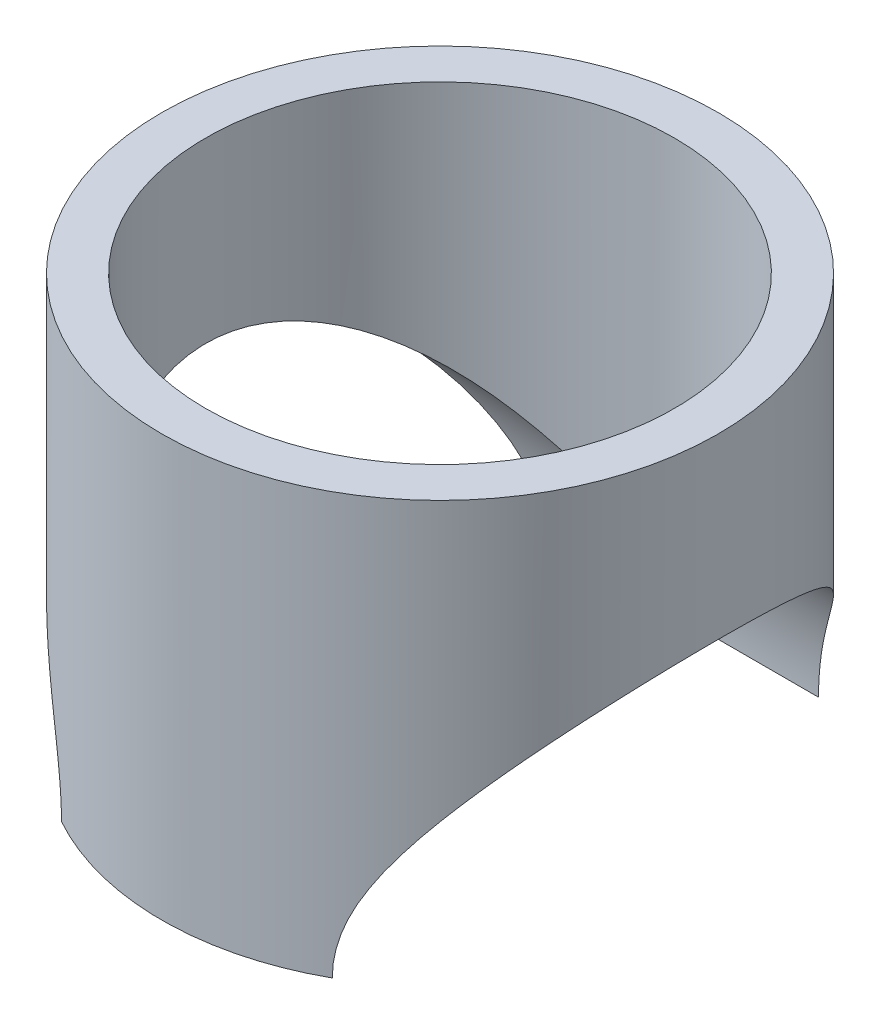
from build123d import *

# Parameters (mm, degrees)
SKETCH1_R           = 24.13
SKETCH1_R_2         = 20.32
BOSS_EXTRUDE1_DEPTH = 18.25625
SKETCH6_W           = 21.082
SKETCH6_H           = 24.13


with BuildPart() as part:
    # Sketch1 → Boss-Extrude1 (new body, symmetric)
    with BuildSketch(Plane(origin=(0, 0, 0), x_dir=(1, 0, 0), z_dir=(0, 1, 0))):
        Circle(SKETCH1_R)
        Circle(SKETCH1_R_2, mode=Mode.SUBTRACT)
    extrude(amount=BOSS_EXTRUDE1_DEPTH, both=True)

    # Sketch6 → 3/32 (1.66) Dowel Hole1 (revolve, cut)
    with BuildSketch(Plane(origin=(0, -18.25625, 0), x_dir=(0, 0, -1), z_dir=(0, 1, 0))):
        with Locations((10.541, 12.065)):
            Rectangle(SKETCH6_W, SKETCH6_H)
    f_3_32_1_66_dowel_hole1 = revolve(axis=Axis((6.35, -18.25625, 0), (-1, 0, 0)), mode=Mode.SUBTRACT)

    # Mirror1: 3/32 (1.66) Dowel Hole1 across plane
    add(f_3_32_1_66_dowel_hole1.mirror(Plane(origin=(0, 0, 0), x_dir=(0, 0, 1), z_dir=(1, 0, 0))), mode=Mode.SUBTRACT)


solid = part.part
